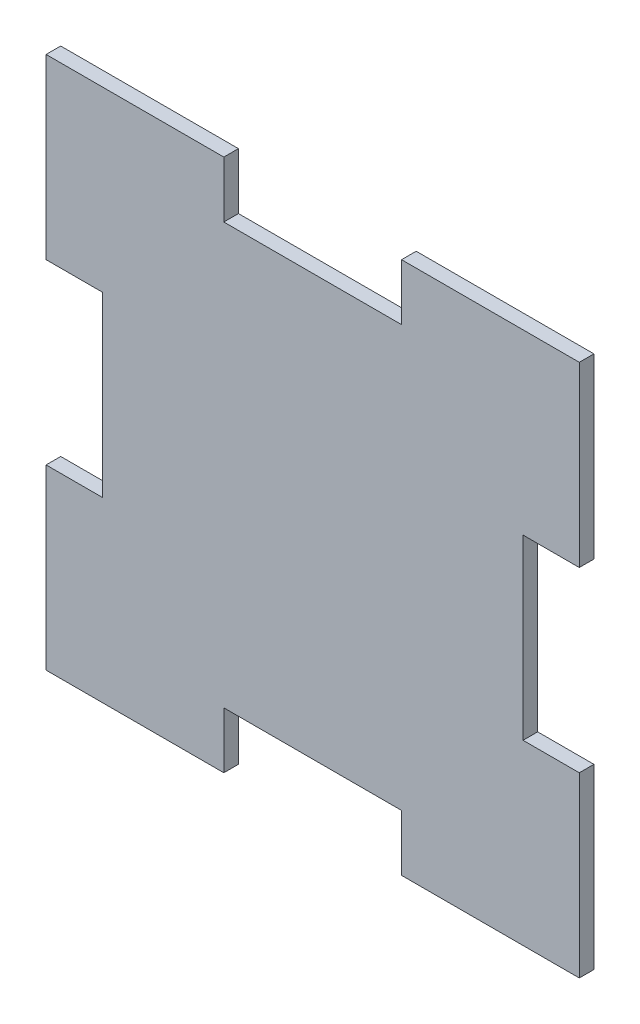
from build123d import *

# Parameters (mm, degrees)
BOSS_EXTRUDE1_DEPTH = 2.6
SKETCH2_W           = 10
SKETCH2_H           = 31.6
SKETCH2_W_2         = 31.6
SKETCH2_H_2         = 10
CUT_EXTRUDE1_DEPTH  = 3.6


with BuildPart() as part:
    # Sketch1 → Boss-Extrude1 (new body)
    with BuildSketch(Plane.XY):
        Polygon((1.120381921, 67.197647161), (1.120381921, 32.237647161), (1.120381921, 2.317647161), (31.040381921, 2.317647161), (66.000381921, 2.317647161), (95.920381921, 2.317647161), (95.920381921, 32.237647161), (95.920381921, 62.157647161), (95.920381921, 97.117647161), (60.960381921, 97.117647161), (31.040381921, 97.117647161), (1.120381921, 97.117647161), align=None)
    extrude(amount=BOSS_EXTRUDE1_DEPTH)

    # Sketch2 → Cut-Extrude1 (cut, through all)
    with BuildSketch(Plane.XY.offset(2.6)):
        with Locations((6.120381921, 49.717647161)):
            Rectangle(SKETCH2_W, SKETCH2_H)
        with Locations((90.920381921, 49.717647161)):
            Rectangle(SKETCH2_W, SKETCH2_H)
        with Locations((48.520381921, 92.117647161)):
            Rectangle(SKETCH2_W_2, SKETCH2_H_2)
        with Locations((48.520381921, 7.317647161)):
            Rectangle(SKETCH2_W_2, SKETCH2_H_2)
    extrude(amount=-CUT_EXTRUDE1_DEPTH, mode=Mode.SUBTRACT)


solid = part.part
